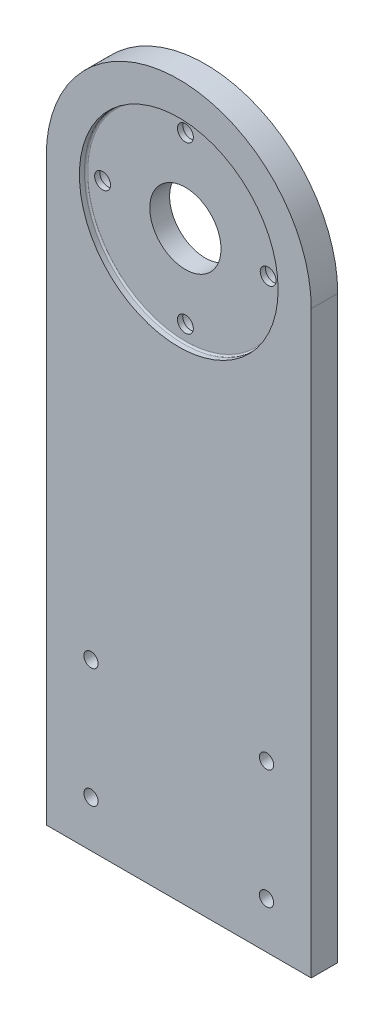
from build123d import *

# Parameters (mm, degrees)
SKETCH1_R                                           = 5
BOSS_EXTRUDE1_DEPTH                                 = 8
M4_CLEARANCE_HOLE1_D                                = 4.3
F_20_0MM_TRANSITIONAL_DOWEL_HOLE1_D                 = 21.5
CBORE_FOR_M4_HEX_SOCKET_HEAD_CAP_SCREW3_D           = 4.8
CBORE_FOR_M4_HEX_SOCKET_HEAD_CAP_SCREW3_CBORE_D     = 8
CBORE_FOR_M4_HEX_SOCKET_HEAD_CAP_SCREW3_CBORE_DEPTH = 4.4
SKETCH12_R                                          = 30
CUT_EXTRUDE1_DEPTH                                  = 2
FILLET1_R                                           = 0.5


with BuildPart() as part:
    # Sketch1 → Boss-Extrude1 (new body)
    with BuildSketch(Plane.XY):
        with BuildLine():
            Line((0, 0), (-80, 0))
            Line((-80, 0), (-80, 175))
            ThreePointArc((-80, 175), (-40, 215), (0, 175))
            Line((0, 175), (0, 0))
        make_face()
        with Locations((-40, 175)):
            Circle(SKETCH1_R, mode=Mode.SUBTRACT)
    extrude(amount=BOSS_EXTRUDE1_DEPTH)

    # M4 Clearance Hole1 (through all)
    with Locations(Plane.XY.offset(8)):
        with Locations((-66.5, 14), (-13.5, 14), (-13.5, 50), (-66.5, 50)):
            Hole(M4_CLEARANCE_HOLE1_D / 2)

    # Ø20.0mm Transitional Dowel Hole1 (through all)
    with Locations(Plane.XY.offset(8)):
        with Locations((-40, 175)):
            Hole(F_20_0MM_TRANSITIONAL_DOWEL_HOLE1_D / 2)

    # CBORE for M4 Hex Socket Head Cap Screw3 (through all)
    with Locations(Plane(origin=(0, 0, 0), x_dir=(1, 0, 0), z_dir=(0, 0, -1))):
        with Locations((-40, -200), (-15.000221056, -174.999778948), (-40.000442109, -150.000000004), (-65.000221052, -175.000221056)):
            CounterBoreHole(CBORE_FOR_M4_HEX_SOCKET_HEAD_CAP_SCREW3_D / 2, CBORE_FOR_M4_HEX_SOCKET_HEAD_CAP_SCREW3_CBORE_D / 2, CBORE_FOR_M4_HEX_SOCKET_HEAD_CAP_SCREW3_CBORE_DEPTH)

    # Sketch12 → Cut-Extrude1 (cut)
    with BuildSketch(Plane.XY.offset(8)):
        with Locations((-40, 175)):
            Circle(SKETCH12_R)
    extrude(amount=-CUT_EXTRUDE1_DEPTH, mode=Mode.SUBTRACT)

    # Fillet1
    fillet1_edges = [part.edges().sort_by_distance(p)[0] for p in [
        (-70, 175, 6),
    ]]
    fillet(fillet1_edges, radius=FILLET1_R)


solid = part.part
